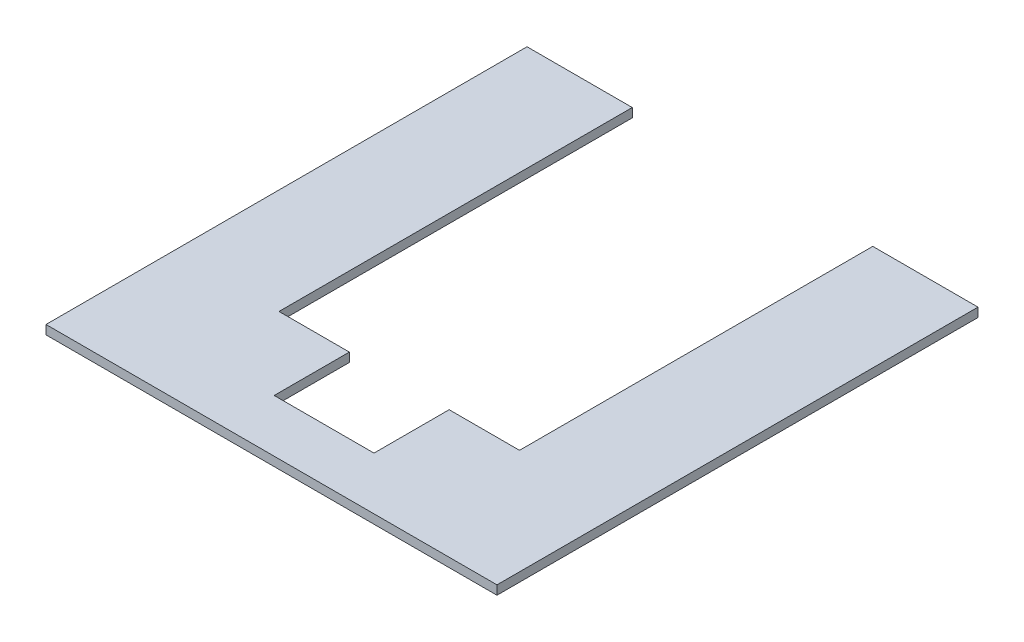
from build123d import *

# Parameters (mm, degrees)
SKETCH3_W           = 150
SKETCH3_H           = 150
BOSS_EXTRUDE1_DEPTH = 3
SKETCH4_W           = 80
SKETCH4_H           = 80
CUT_EXTRUDE1_DEPTH  = 3
SKETCH5_W           = 35
SKETCH5_H           = 3
BOSS_EXTRUDE2_DEPTH = 10
SKETCH7_W           = 80
SKETCH7_H           = 3
CUT_EXTRUDE2_DEPTH  = 27.5
SKETCH8_W           = 33.2
SKETCH8_H           = 25
CUT_EXTRUDE3_DEPTH  = 3


with BuildPart() as part:
    # Sketch3 → Boss-Extrude1 (new body)
    with BuildSketch(Plane(origin=(0, 0, 0), x_dir=(1, 0, 0), z_dir=(0, 1, 0))):
        Rectangle(SKETCH3_W, SKETCH3_H)
    extrude(amount=BOSS_EXTRUDE1_DEPTH)

    # Sketch4 → Cut-Extrude1 (cut)
    with BuildSketch(Plane(origin=(0, 3, 0), x_dir=(1, 0, 0), z_dir=(0, 1, 0))):
        with Locations((0, 35)):
            Rectangle(SKETCH4_W, SKETCH4_H)
    extrude(amount=-CUT_EXTRUDE1_DEPTH, mode=Mode.SUBTRACT)

    # Sketch5 → Boss-Extrude2 (add)
    with BuildSketch(Plane(origin=(0, 0, -75), x_dir=(-1, 0, 0), z_dir=(0, 0, -1))):
        with Locations((-57.5, 1.5)):
            Rectangle(SKETCH5_W, SKETCH5_H)
        with Locations((57.5, 1.5)):
            Rectangle(SKETCH5_W, SKETCH5_H)
    extrude(amount=BOSS_EXTRUDE2_DEPTH)

    # Sketch7 → Cut-Extrude2 (cut)
    with BuildSketch(Plane(origin=(0, 0, 5), x_dir=(-1, 0, 0), z_dir=(0, 0, -1))):
        with Locations((0, 1.5)):
            Rectangle(SKETCH7_W, SKETCH7_H)
    extrude(amount=-CUT_EXTRUDE2_DEPTH, mode=Mode.SUBTRACT)

    # Sketch8 → Cut-Extrude3 (cut)
    with BuildSketch(Plane(origin=(0, 3, 0), x_dir=(1, 0, 0), z_dir=(0, 1, 0))):
        with Locations((0, -45)):
            Rectangle(SKETCH8_W, SKETCH8_H)
    extrude(amount=-CUT_EXTRUDE3_DEPTH, mode=Mode.SUBTRACT)


solid = part.part
